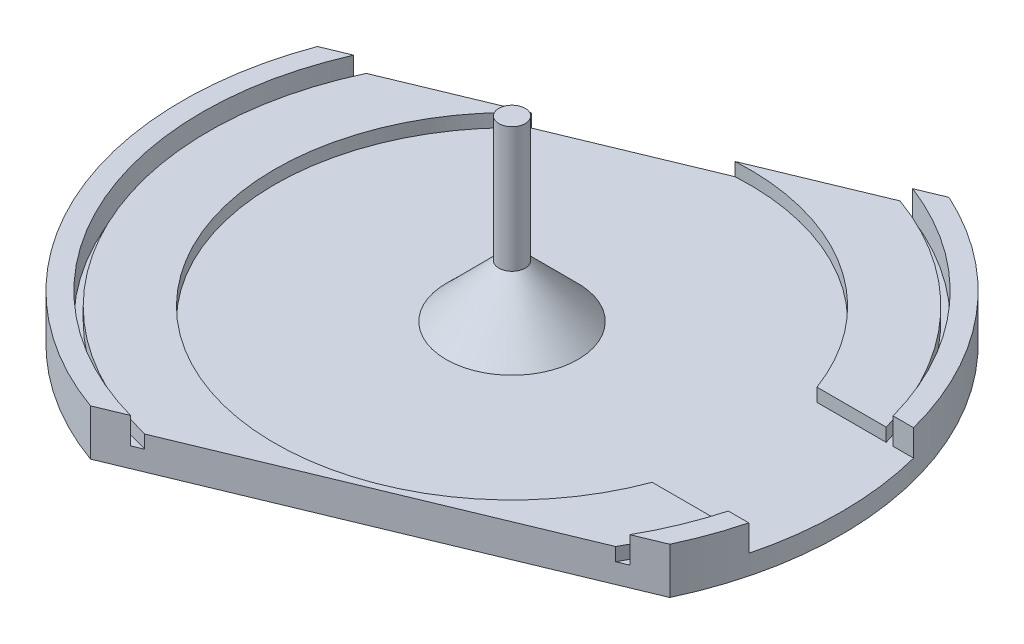
from build123d import *

# Parameters (mm, degrees)
SKETCH1_R           = 50
BOSS_EXTRUDE1_DEPTH = 3
SKETCH2_R           = 50
SKETCH2_R_2         = 47
BOSS_EXTRUDE2_DEPTH = 4
SKETCH3_R           = 2
BOSS_EXTRUDE3_DEPTH = 27
CHAMFER1_SIZE       = 8
SKETCH4_R           = 46
SKETCH4_R_2         = 36
BOSS_EXTRUDE4_DEPTH = 2
CUT_EXTRUDE1_START  = 80
SKETCH5_W           = 25
SKETCH5_H           = 8
CUT_EXTRUDE1_DEPTH  = 59
CUT_EXTRUDE2_DEPTH  = 10
CUT_EXTRUDE3_DEPTH  = 10


with BuildPart() as part:
    # Sketch1 → Boss-Extrude1 (new body)
    with BuildSketch(Plane(origin=(0, 0, 0), x_dir=(1, 0, 0), z_dir=(0, 1, 0))):
        Circle(SKETCH1_R)
    extrude(amount=BOSS_EXTRUDE1_DEPTH)

    # Sketch2 → Boss-Extrude2 (add)
    with BuildSketch(Plane(origin=(0, 3, 0), x_dir=(1, 0, 0), z_dir=(0, 1, 0))):
        Circle(SKETCH2_R)
        Circle(SKETCH2_R_2, mode=Mode.SUBTRACT)
    extrude(amount=BOSS_EXTRUDE2_DEPTH)

    # Sketch3 → Boss-Extrude3 (add)
    with BuildSketch(Plane(origin=(0, 3, 0), x_dir=(1, 0, 0), z_dir=(0, 1, 0))):
        Circle(SKETCH3_R)
    extrude(amount=BOSS_EXTRUDE3_DEPTH)

    # Chamfer1
    chamfer1_edges = [part.edges().sort_by_distance(p)[0] for p in [
        (-2, 3, 0),
    ]]
    chamfer(chamfer1_edges, length=CHAMFER1_SIZE)

    # Sketch4 → Boss-Extrude4 (add)
    with BuildSketch(Plane(origin=(0, 3, 0), x_dir=(1, 0, 0), z_dir=(0, 1, 0))):
        Circle(SKETCH4_R)
        Circle(SKETCH4_R_2, mode=Mode.SUBTRACT)
    extrude(amount=BOSS_EXTRUDE4_DEPTH)

    # Sketch5 → Cut-Extrude1 (cut)
    with BuildSketch(Plane(origin=(0, 0, 0), x_dir=(0, 0, -1), z_dir=(1, 0, 0)).offset(CUT_EXTRUDE1_START)):
        with Locations((0, 7)):
            Rectangle(SKETCH5_W, SKETCH5_H)
    extrude(amount=-CUT_EXTRUDE1_DEPTH, mode=Mode.SUBTRACT)

    # Sketch7 → Cut-Extrude2 (cut)
    with BuildSketch(Plane.XZ):
        with BuildLine():
            Line((-119.395726794, 97.143761629), (-5.083168687, 49.740942855))
            ThreePointArc((-5.083168687, 49.740942855), (19.152450403, 46.186401067), (38.791481396, 31.547123024))
            Line((38.791481396, 31.547123024), (134.629479077, -8.194715589))
            Line((134.629479077, -8.194715589), (149.847747334, 28.504350406))
            Line((149.847747334, 28.504350406), (-104.177458536, 133.842827624))
            Line((-104.177458536, 133.842827624), (-119.395726794, 97.143761629))
        make_face()
        with BuildLine():
            ThreePointArc((38.791481396, 31.547123024), (41.025780027, 28.581206642), (43.033800963, 25.457650612))
            Line((43.033800963, 25.457650612), (133.097283044, -11.889627674))
            Line((133.097283044, -11.889627674), (134.629479077, -8.194715589))
            Line((134.629479077, -8.194715589), (38.791481396, 31.547123024))
        make_face()
        with BuildLine():
            ThreePointArc((38.791481396, 31.547123024), (19.152450403, 46.186401067), (-5.083168687, 49.740942855))
            Line((-5.083168687, 49.740942855), (38.791481396, 31.547123024))
        make_face()
        with BuildLine():
            ThreePointArc((-5.083168687, 49.740942855), (-8.76068428, 49.226521418), (-12.389880318, 48.440591096))
            Line((-12.389880318, 48.440591096), (43.033800963, 25.457650612))
            ThreePointArc((43.033800963, 25.457650612), (41.025780027, 28.581206642), (38.791481396, 31.547123024))
            Line((38.791481396, 31.547123024), (-5.083168687, 49.740942855))
        make_face()
        with BuildLine():
            Line((-120.927922826, 93.448849543), (-12.389880318, 48.440591096))
            ThreePointArc((-12.389880318, 48.440591096), (-8.76068428, 49.226521418), (-5.083168687, 49.740942855))
            Line((-5.083168687, 49.740942855), (-119.395726794, 97.143761629))
            Line((-119.395726794, 97.143761629), (-120.927922826, 93.448849543))
        make_face()
        with BuildLine():
            Line((-11.858515668, -55.706448378), (84.665757499, -95.732869831))
            Line((84.665757499, -95.732869831), (92.00979772, -81.45716056))
            Line((92.00979772, -81.45716056), (86.695290109, -79.253355087))
            Line((86.695290109, -79.253355087), (87.844437133, -76.482171023))
            Line((87.844437133, -76.482171023), (16.892477306, -47.060006486))
            ThreePointArc((16.892477306, -47.060006486), (-19.152450403, -46.186401067), (-45.238103903, -21.295867094))
            Line((-45.238103903, -21.295867094), (-140.17236541, 18.071212676))
            Line((-140.17236541, 18.071212676), (-142.248536864, 13.06449628))
            Line((-142.248536864, 13.06449628), (-142.248536864, 11.37179915))
            Line((-142.248536864, 11.37179915), (-11.858515668, -55.706448378))
        make_face()
        with BuildLine():
            ThreePointArc((-45.238103903, -21.295867094), (-19.152450403, -46.186401067), (16.892477306, -47.060006486))
            Line((16.892477306, -47.060006486), (-45.238103903, -21.295867094))
        make_face()
    extrude(amount=-CUT_EXTRUDE2_DEPTH, mode=Mode.SUBTRACT)

    # Sketch8 → Cut-Extrude3 (cut)
    with BuildSketch(Plane.XZ):
        with BuildLine():
            ThreePointArc((16.892477306, -47.060006486), (18.883795364, -46.296892689), (20.840762361, -45.44956132))
            Line((20.840762361, -45.44956132), (18.04162433, -44.288822422))
            Line((18.04162433, -44.288822422), (-44.088956879, -18.52468303))
            Line((-44.088956879, -18.52468303), (-46.888094909, -17.363944131))
            ThreePointArc((-46.888094909, -17.363944131), (-46.105033689, -19.347502903), (-45.238103903, -21.295867094))
            Line((-45.238103903, -21.295867094), (16.892477306, -47.060006486))
        make_face()
        with BuildLine():
            Line((41.387159819, 22.892766048), (41.884653939, 22.686466548))
            Line((41.884653939, 22.686466548), (45.238103903, 21.295867094))
            ThreePointArc((45.238103903, 21.295867094), (44.184979435, 23.402726173), (43.033800963, 25.457650612))
            Line((43.033800963, 25.457650612), (-12.389880318, 48.440591096))
            ThreePointArc((-12.389880318, 48.440591096), (-14.657442494, 47.803340673), (-16.892477306, 47.060006486))
            Line((-16.892477306, 47.060006486), (-13.539027342, 45.669407032))
            Line((-13.539027342, 45.669407032), (-11.390013124, 44.778259697))
            Line((-11.390013124, 44.778259697), (41.387159819, 22.892766048))
        make_face()
    extrude(amount=-CUT_EXTRUDE3_DEPTH, mode=Mode.SUBTRACT)


solid = part.part
